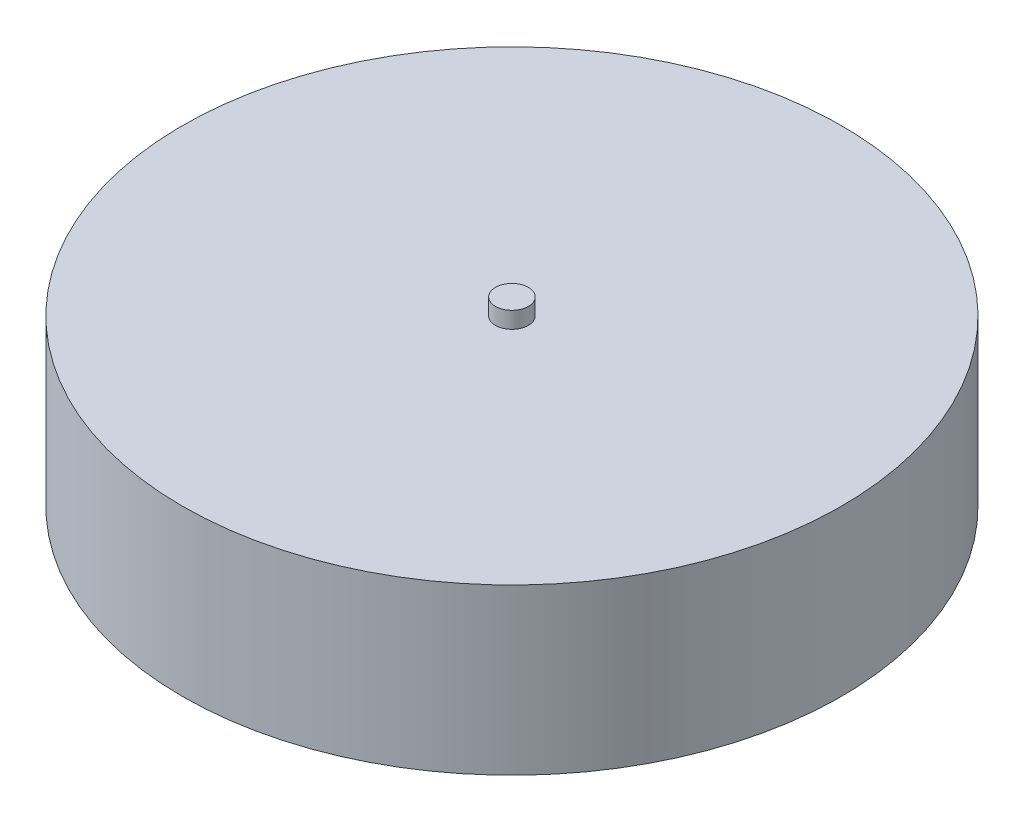
from build123d import *

# Parameters (mm, degrees)
SKETCH1_R                = 200
BOSS_EXTRUDE1_DEPTH      = 100
BOSS_EXTRUDE2_DEPTH      = 110
BOSS_EXTRUDE2_DEPTH_BACK = 10
SKETCH1_3_R              = 10


with BuildPart() as part:
    # Sketch1 → Boss-Extrude1 (new body)
    with BuildSketch(Plane(origin=(0, 0, 0), x_dir=(1, 0, 0), z_dir=(0, 1, 0))):
        Circle(SKETCH1_R)
    extrude(amount=BOSS_EXTRUDE1_DEPTH)


with BuildPart() as body_2:
    # Sketch1_3 → Boss-Extrude2 (new, two sides: drawn at the far end of the back side and taken through both)
    with BuildSketch(Plane(origin=(0, 0, 0), x_dir=(1, 0, 0), z_dir=(0, 1, 0)).offset(-BOSS_EXTRUDE2_DEPTH_BACK)):
        Circle(SKETCH1_3_R)
    extrude(amount=BOSS_EXTRUDE2_DEPTH + BOSS_EXTRUDE2_DEPTH_BACK)


solid = Compound([part.part, body_2.part])
